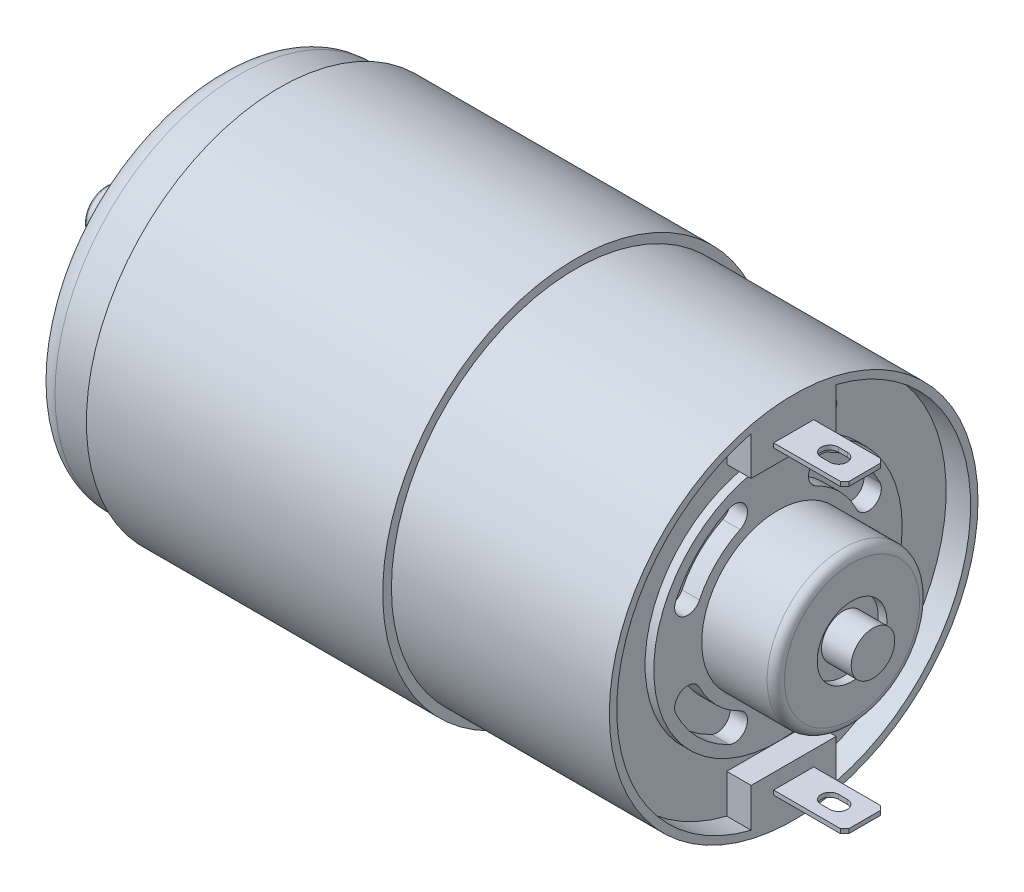
from build123d import *

# Parameters (mm, degrees)
SKETCH1_W                   = 34
SKETCH1_H                   = 22.15
SKETCH2_R                   = 21.15
BOSS_EXTRUDE1_DEPTH         = 25
SKETCH3_W                   = 4.6
SKETCH3_H                   = 0.5
BOSS_EXTRUDE2_DEPTH         = 8.15
CUT_EXTRUDE1_DEPTH          = 40.65
SKETCH5_W                   = 4.6
SKETCH5_H                   = 0.5
BOSS_EXTRUDE3_DEPTH         = 8.15
CUT_EXTRUDE2_REACH          = 41.65
CUT_EXTRUDE3_DEPTH          = 2.8
SKETCH8_R                   = 14.25
BOSS_EXTRUDE4_DEPTH         = 1
CUT_EXTRUDE4_DEPTH          = 2
CUT_EXTRUDE5_DEPTH          = 2
CUT_EXTRUDE6_DEPTH          = 2
CUT_EXTRUDE7_DEPTH          = 2
SKETCH13_R                  = 21.15
BOSS_EXTRUDE5_DEPTH         = 7.1
CUT_EXTRUDE8_DEPTH          = 10
CUT_EXTRUDE9_DEPTH          = 10
CUT_EXTRUDE10_DEPTH         = 10
CUT_EXTRUDE11_DEPTH         = 10
SKETCH18_R                  = 8.75
BOSS_EXTRUDE6_DEPTH         = 8.5
HOLE1_D                     = 8
HOLE1_DEPTH                 = 1
SKETCH21_R                  = 8.9
BOSS_EXTRUDE7_DEPTH         = 5
F_1_2_CLEARANCE_HOLE1_D     = 13.25
F_1_2_CLEARANCE_HOLE1_DEPTH = 1
SKETCH25_W                  = 3.4
SKETCH25_H                  = 2.5
F_2_CLEARANCE_HOLE1_D       = 2.5
F_2_CLEARANCE_HOLE1_DEPTH   = 0.1
F_4_CLEARANCE_HOLE1_D       = 3.3
F_4_CLEARANCE_HOLE1_DEPTH   = 11.5
F_4_CLEARANCE_HOLE1_TIP     = 0.991420021
CHAMFER1_SIZE               = 0.5
FILLET1_R                   = 0.25
FILLET2_R                   = 0.75
FILLET3_R                   = 1
FILLET4_R                   = 2.5


with BuildPart() as part:
    # Sketch1 → Revolve1 (revolve)
    with BuildSketch(Plane.XY):
        with Locations((24.1, 11.075)):
            Rectangle(SKETCH1_W, SKETCH1_H)
    revolve(axis=Axis((7.1, 0, 0), (1, 0, 0)))

    # Sketch2 → Boss-Extrude1 (add)
    with BuildSketch(Plane(origin=(41.1, 0, 0), x_dir=(0, 0, -1), z_dir=(1, 0, 0))):
        Circle(SKETCH2_R)
    extrude(amount=BOSS_EXTRUDE1_DEPTH)

    # Sketch3 → Boss-Extrude2 (add)
    with BuildSketch(Plane(origin=(66.1, 0, 0), x_dir=(0, 0, -1), z_dir=(1, 0, 0))):
        with Locations((0, 17.25)):
            Rectangle(SKETCH3_W, SKETCH3_H)
    extrude(amount=BOSS_EXTRUDE2_DEPTH)

    # Sketch4 → Cut-Extrude1 (cut, through all)
    with BuildSketch(Plane(origin=(0, 17.5, 0), x_dir=(-1, 0, 0), z_dir=(0, 1, 0))):
        with BuildLine():
            Line((-71.25, -1), (-70.25, -1))
            ThreePointArc((-70.25, -1), (-69.25, 0), (-70.25, 1))
            Line((-70.25, 1), (-71.25, 1))
            ThreePointArc((-71.25, 1), (-72.25, 0), (-71.25, -1))
        make_face()
    extrude(amount=-CUT_EXTRUDE1_DEPTH, mode=Mode.SUBTRACT)

    # Sketch5 → Boss-Extrude3 (add)
    with BuildSketch(Plane(origin=(66.1, 0, 0), x_dir=(0, 0, -1), z_dir=(1, 0, 0))):
        with Locations((0, -17.25)):
            Rectangle(SKETCH5_W, SKETCH5_H)
    extrude(amount=BOSS_EXTRUDE3_DEPTH)

    # Sketch6 → Cut-Extrude2 (cut, up to next)
    with BuildSketch(Plane.XZ.offset(17.5), mode=Mode.PRIVATE) as cut_extrude2_sk1:
        with BuildLine():
            Line((71.25, 1), (70.25, 1))
            ThreePointArc((70.25, 1), (69.25, 0), (70.25, -1))
            Line((70.25, -1), (71.25, -1))
            ThreePointArc((71.25, -1), (72.25, 0), (71.25, 1))
        make_face()
    cut_extrude2_tool1 = extrude(cut_extrude2_sk1.sketch, amount=-CUT_EXTRUDE2_REACH, mode=Mode.PRIVATE) & part.part
    add(cut_extrude2_tool1.solids().sort_by_distance((70.75, -17.5, 0))[0], mode=Mode.SUBTRACT)

    # Sketch7 → Cut-Extrude3 (cut)
    with BuildSketch(Plane(origin=(66.1, 0, 0), x_dir=(0, 0, -1), z_dir=(1, 0, 0))):
        with BuildLine():
            Line((2.068879475, 14.25), (2.068879475, 15.25))
            Line((2.068879475, 15.25), (-4.875, 15.25))
            Line((-4.875, 15.25), (-4.875, 19.705947706))
            ThreePointArc((-4.875, 19.705947706), (-20.3, 0), (-4.875, -19.705947706))
            Line((-4.875, -19.705947706), (-4.875, -15.25))
            Line((-4.875, -15.25), (4.875, -15.25))
            Line((4.875, -15.25), (4.875, -19.705947706))
            ThreePointArc((4.875, -19.705947706), (20.3, 0), (4.875, 19.705947706))
            Line((4.875, 19.705947706), (4.875, 14.25))
            Line((4.875, 14.25), (2.068879475, 14.25))
        make_face()
    extrude(amount=-CUT_EXTRUDE3_DEPTH, mode=Mode.SUBTRACT)

    # Sketch8 → Boss-Extrude4 (add)
    with BuildSketch(Plane(origin=(63.3, 0, 0), x_dir=(0, 0, -1), z_dir=(1, 0, 0))):
        Circle(SKETCH8_R)
    extrude(amount=BOSS_EXTRUDE4_DEPTH)

    # Sketch9 → Cut-Extrude4 (cut)
    with BuildSketch(Plane(origin=(64.3, 0, 0), x_dir=(0, 0, -1), z_dir=(1, 0, 0))):
        with BuildLine():
            ThreePointArc((-5.652173913, 11.706960752), (-9.192388155, 9.192388155), (-11.706960752, 5.652173913))
            ThreePointArc((-11.706960752, 5.652173913), (-11.008331502, 3.649196836), (-9.005354425, 4.347826087))
            ThreePointArc((-9.005354425, 4.347826087), (-7.071067812, 7.071067812), (-4.347826087, 9.005354425))
            ThreePointArc((-4.347826087, 9.005354425), (-3.649196836, 11.008331502), (-5.652173913, 11.706960752))
        make_face()
    extrude(amount=-CUT_EXTRUDE4_DEPTH, mode=Mode.SUBTRACT)

    # Sketch10 → Cut-Extrude5 (cut)
    with BuildSketch(Plane(origin=(64.3, 0, 0), x_dir=(0, 0, -1), z_dir=(1, 0, 0))):
        with BuildLine():
            ThreePointArc((11.706960752, 5.652173913), (9.192388155, 9.192388155), (5.652173913, 11.706960752))
            ThreePointArc((5.652173913, 11.706960752), (3.649196836, 11.008331502), (4.347826087, 9.005354425))
            ThreePointArc((4.347826087, 9.005354425), (7.071067812, 7.071067812), (9.005354425, 4.347826087))
            ThreePointArc((9.005354425, 4.347826087), (11.008331502, 3.649196836), (11.706960752, 5.652173913))
        make_face()
    extrude(amount=-CUT_EXTRUDE5_DEPTH, mode=Mode.SUBTRACT)

    # Sketch11 → Cut-Extrude6 (cut)
    with BuildSketch(Plane(origin=(64.3, 0, 0), x_dir=(0, 0, -1), z_dir=(1, 0, 0))):
        with BuildLine():
            ThreePointArc((5.652173913, -11.706960752), (9.192388155, -9.192388155), (11.706960752, -5.652173913))
            ThreePointArc((11.706960752, -5.652173913), (11.008331502, -3.649196836), (9.005354425, -4.347826087))
            ThreePointArc((9.005354425, -4.347826087), (7.071067812, -7.071067812), (4.347826087, -9.005354425))
            ThreePointArc((4.347826087, -9.005354425), (3.649196836, -11.008331502), (5.652173913, -11.706960752))
        make_face()
    extrude(amount=-CUT_EXTRUDE6_DEPTH, mode=Mode.SUBTRACT)

    # Sketch12 → Cut-Extrude7 (cut)
    with BuildSketch(Plane(origin=(64.3, 0, 0), x_dir=(0, 0, -1), z_dir=(1, 0, 0))):
        with BuildLine():
            ThreePointArc((-11.706960752, -5.652173913), (-9.192388155, -9.192388155), (-5.652173913, -11.706960752))
            ThreePointArc((-5.652173913, -11.706960752), (-3.649196836, -11.008331502), (-4.347826087, -9.005354425))
            ThreePointArc((-4.347826087, -9.005354425), (-7.071067812, -7.071067812), (-9.005354425, -4.347826087))
            ThreePointArc((-9.005354425, -4.347826087), (-11.008331502, -3.649196836), (-11.706960752, -5.652173913))
        make_face()
    extrude(amount=-CUT_EXTRUDE7_DEPTH, mode=Mode.SUBTRACT)

    # Sketch13 → Boss-Extrude5 (add)
    with BuildSketch(Plane.ZY.offset(-7.1)):
        Circle(SKETCH13_R)
    extrude(amount=BOSS_EXTRUDE5_DEPTH)

    # Sketch14 → Cut-Extrude8 (cut)
    with BuildSketch(Plane.ZY):
        with BuildLine():
            Line((6.761892188, 14.500924593), (4.775586358, 10.241277994))
            ThreePointArc((4.775586358, 10.241277994), (7.990306627, 7.990306627), (10.241277994, 4.775586358))
            Line((10.241277994, 4.775586358), (14.500924593, 6.761892188))
            ThreePointArc((14.500924593, 6.761892188), (11.313708499, 11.313708499), (6.761892188, 14.500924593))
        make_face()
    extrude(amount=-CUT_EXTRUDE8_DEPTH, mode=Mode.SUBTRACT)

    # Sketch15 → Cut-Extrude9 (cut)
    with BuildSketch(Plane.ZY):
        with BuildLine():
            Line((-6.761892188, -14.500924593), (-4.775586358, -10.241277994))
            ThreePointArc((-4.775586358, -10.241277994), (-7.990306627, -7.990306627), (-10.241277994, -4.775586358))
            Line((-10.241277994, -4.775586358), (-14.500924593, -6.761892188))
            ThreePointArc((-14.500924593, -6.761892188), (-11.313708499, -11.313708499), (-6.761892188, -14.500924593))
        make_face()
    extrude(amount=-CUT_EXTRUDE9_DEPTH, mode=Mode.SUBTRACT)

    # Sketch16 → Cut-Extrude10 (cut)
    with BuildSketch(Plane.ZY):
        with BuildLine():
            Line((-14.500924593, 6.761892188), (-10.241277994, 4.775586358))
            ThreePointArc((-10.241277994, 4.775586358), (-7.990306627, 7.990306627), (-4.775586358, 10.241277994))
            Line((-4.775586358, 10.241277994), (-6.761892188, 14.500924593))
            ThreePointArc((-6.761892188, 14.500924593), (-11.313708499, 11.313708499), (-14.500924593, 6.761892188))
        make_face()
    extrude(amount=-CUT_EXTRUDE10_DEPTH, mode=Mode.SUBTRACT)

    # Sketch17 → Cut-Extrude11 (cut)
    with BuildSketch(Plane.ZY):
        with BuildLine():
            Line((14.500924593, -6.761892188), (10.241277994, -4.775586358))
            ThreePointArc((10.241277994, -4.775586358), (7.990306627, -7.990306627), (4.775586358, -10.241277994))
            Line((4.775586358, -10.241277994), (6.761892188, -14.500924593))
            ThreePointArc((6.761892188, -14.500924593), (11.313708499, -11.313708499), (14.500924593, -6.761892188))
        make_face()
    extrude(amount=-CUT_EXTRUDE11_DEPTH, mode=Mode.SUBTRACT)

    # Sketch18 → Boss-Extrude6 (add)
    with BuildSketch(Plane(origin=(64.3, 0, 0), x_dir=(0, 0, -1), z_dir=(1, 0, 0))):
        Circle(SKETCH18_R)
    extrude(amount=BOSS_EXTRUDE6_DEPTH)

    # Hole1
    with Locations(Plane(origin=(72.8, 0, 0), x_dir=(0, 0, -1), z_dir=(1, 0, 0))):
        with Locations((0, 0)):
            Hole(HOLE1_D / 2, depth=HOLE1_DEPTH)

    # Sketch21 → Boss-Extrude7 (add)
    with BuildSketch(Plane.ZY):
        Circle(SKETCH21_R)
    extrude(amount=BOSS_EXTRUDE7_DEPTH)

    # 1/2 Clearance Hole1
    with Locations(Plane.ZY.offset(5)):
        with Locations((0, 0)):
            Hole(F_1_2_CLEARANCE_HOLE1_D / 2, depth=F_1_2_CLEARANCE_HOLE1_DEPTH)

    # Sketch24 → Revolve2 (revolve)
    with BuildSketch(Plane(origin=(0, 0, 0), x_dir=(-1, 0, 0), z_dir=(0, 0, -1))):
        Polygon((4, 3.75), (4, 0), (12.8, 0), (12.8, 2.5), (5, 2.5), (5, 3.75), align=None)
    revolve(axis=Axis((-4, 0, 0), (-1, 0, 0)))

    # Sketch25 → Revolve3 (revolve)
    with BuildSketch(Plane(origin=(0, 0, 0), x_dir=(-1, 0, 0), z_dir=(0, 0, -1))):
        with Locations((-73.5, 1.25)):
            Rectangle(SKETCH25_W, SKETCH25_H)
    revolve(axis=Axis((75.2, 0, 0), (-1, 0, 0)))

    # #2 Clearance Hole1
    with Locations(Plane(origin=(63.3, 0, 0), x_dir=(0, 0, -1), z_dir=(1, 0, 0))):
        with Locations((6.5, 15)):
            Hole(F_2_CLEARANCE_HOLE1_D / 2, depth=F_2_CLEARANCE_HOLE1_DEPTH)

    # #4 Clearance Hole1
    with Locations(Plane.ZY):
        with Locations((0, 14.5), (0, -14.5)):
            Hole(F_4_CLEARANCE_HOLE1_D / 2, depth=F_4_CLEARANCE_HOLE1_DEPTH)
            with Locations((0, 0, -(F_4_CLEARANCE_HOLE1_DEPTH + F_4_CLEARANCE_HOLE1_TIP / 2))):  # 118° drill point
                Cone(0, F_4_CLEARANCE_HOLE1_D / 2, F_4_CLEARANCE_HOLE1_TIP, mode=Mode.SUBTRACT)

    # Chamfer1
    chamfer1_edges = [part.edges().sort_by_distance(p)[0] for p in [
        (74.25, 17.25, -2.3),
        (74.25, 17.25, 2.3),
        (74.25, -17.25, -2.3),
        (74.25, -17.25, 2.3),
    ]]
    chamfer(chamfer1_edges, length=CHAMFER1_SIZE)

    # Fillet1
    fillet1_edges = [part.edges().sort_by_distance(p)[0] for p in [
        (-12.8, -2.5, 0),
    ]]
    fillet(fillet1_edges, radius=FILLET1_R)

    # Fillet2
    fillet2_edges = [part.edges().sort_by_distance(p)[0] for p in [
        (-5, 0, -8.9),
    ]]
    fillet(fillet2_edges, radius=FILLET2_R)

    # Fillet3
    fillet3_edges = [part.edges().sort_by_distance(p)[0] for p in [
        (72.8, 0, 8.75),
    ]]
    fillet(fillet3_edges, radius=FILLET3_R)

    # Fillet4
    fillet4_edges = [part.edges().sort_by_distance(p)[0] for p in [
        (0, 0, -21.15),
    ]]
    fillet(fillet4_edges, radius=FILLET4_R)


solid = part.part
